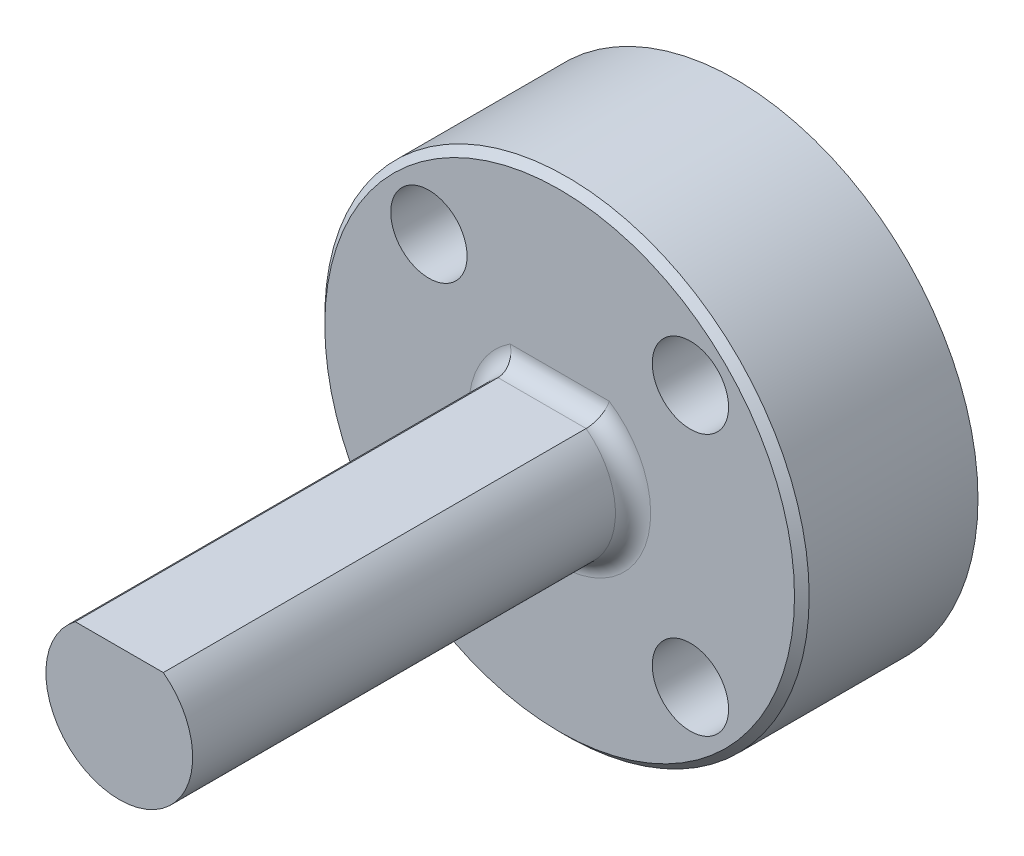
from build123d import *

# Parameters (mm, degrees)
ESQUISSE1_R                  = 10.4775
BOSS_EXTRU_1_DEPTH           = 7.62
ESQUISSE3_R                  = 4.1275
ENL_V_MAT_EXTRU_1_DEPTH      = 2.286
ESQUISSE4_R                  = 2.413
ENL_V_MAT_EXTRU_2_DEPTH      = 2.286
BOSS_EXTRU_2_DEPTH           = 19.05
ESQUISSE6_R                  = 1.27
ENL_V_MAT_EXTRU_3_DEPTH      = 1
ENL_V_MAT_EXTRU_3_DEPTH_BACK = 27.67
ESQUISSE7_R                  = 1.651
ENL_V_MAT_EXTRU_4_DEPTH      = 4.318
CHANFREIN1_SIZE              = 0.3175
CONG_1_R                     = 0.762


with BuildPart() as part:
    # Esquisse1 → Boss.-Extru.1 (new body)
    with BuildSketch(Plane.XY):
        with Locations((0, 12)):
            Circle(ESQUISSE1_R)
    extrude(amount=BOSS_EXTRU_1_DEPTH)

    # Esquisse3 → Enlèv. mat.-Extru.1 (cut)
    with BuildSketch(Plane(origin=(0, 0, 0), x_dir=(-1, 0, 0), z_dir=(0, 0, -1))):
        with Locations((0, 12)):
            Circle(ESQUISSE3_R)
    extrude(amount=-ENL_V_MAT_EXTRU_1_DEPTH, mode=Mode.SUBTRACT)

    # Esquisse4 → Enlèv. mat.-Extru.2 (cut)
    with BuildSketch(Plane(origin=(0, 0, 2.286), x_dir=(-1, 0, 0), z_dir=(0, 0, -1))):
        with Locations((0, 12)):
            Circle(ESQUISSE4_R)
    extrude(amount=-ENL_V_MAT_EXTRU_2_DEPTH, mode=Mode.SUBTRACT)

    # Esquisse5 → Boss.-Extru.2 (add)
    with BuildSketch(Plane.XY.offset(7.62)):
        with BuildLine():
            Line((-1.905, 14.54), (1.905, 14.54))
            ThreePointArc((1.905, 14.54), (0, 8.825), (-1.905, 14.54))
        make_face()
    extrude(amount=BOSS_EXTRU_2_DEPTH)

    # Esquisse6 → Enlèv. mat.-Extru.3 (cut, two sides)
    with BuildSketch(Plane(origin=(0, 0, 0), x_dir=(-1, 0, 0), z_dir=(0, 0, -1))) as enl_v_mat_extru_3_sk:
        with Locations((-5.656854249, 17.656854249)):
            Circle(ESQUISSE6_R)
        with Locations((5.656854249, 17.656854249)):
            Circle(ESQUISSE6_R)
        with Locations((5.656854249, 6.343145751)):
            Circle(ESQUISSE6_R)
        with Locations((-5.656854249, 6.343145751)):
            Circle(ESQUISSE6_R)
    extrude(amount=ENL_V_MAT_EXTRU_3_DEPTH, mode=Mode.SUBTRACT)
    extrude(enl_v_mat_extru_3_sk.sketch, amount=-ENL_V_MAT_EXTRU_3_DEPTH_BACK, mode=Mode.SUBTRACT)

    # Esquisse7 → Enlèv. mat.-Extru.4 (cut)
    with BuildSketch(Plane.XY.offset(7.62)):
        with Locations((-5.656854249, 17.656854249)):
            Circle(ESQUISSE7_R)
        with Locations((5.656854249, 17.656854249)):
            Circle(ESQUISSE7_R)
        with Locations((5.656854249, 6.343145751)):
            Circle(ESQUISSE7_R)
        with Locations((-5.656854249, 6.343145751)):
            Circle(ESQUISSE7_R)
    extrude(amount=-ENL_V_MAT_EXTRU_4_DEPTH, mode=Mode.SUBTRACT)

    # Chanfrein1
    chanfrein1_edges = [part.edges().sort_by_distance(p)[0] for p in [
        (-10.4775, 12, 7.62),
    ]]
    chamfer(chanfrein1_edges, length=CHANFREIN1_SIZE)

    # Congé1
    cong_1_edges = [part.edges().sort_by_distance(p)[0] for p in [
        (0, 8.825, 7.62),
        (0, 14.54, 7.62),
    ]]
    fillet(cong_1_edges, radius=CONG_1_R)


solid = part.part
